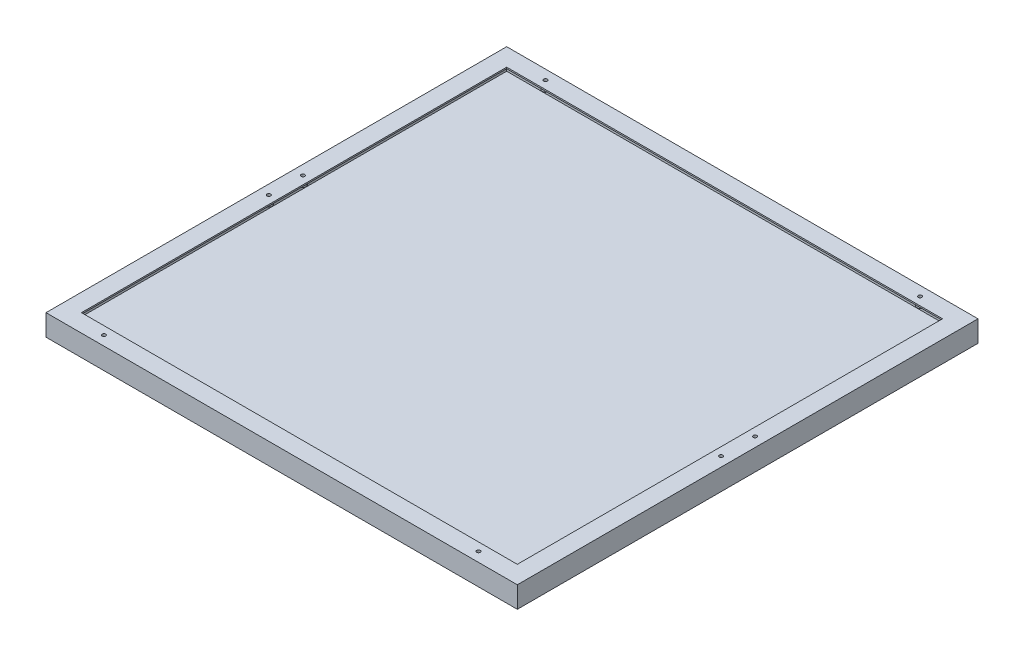
from build123d import *

# Parameters (mm, degrees)
SKETCH1_W                      = 665
SKETCH1_H                      = 650
BOSS_EXTRUDE1_DEPTH            = 30
F_8_0_199_DIAMETER_HOLE1_D     = 5.0546
F_8_0_199_DIAMETER_HOLE1_DEPTH = 9.65
SKETCH4_W                      = 615
SKETCH4_H                      = 600
CUT_EXTRUDE1_DEPTH             = 20
SHELL_T                        = -2


with BuildPart() as part:
    # Sketch1 → Boss-Extrude1 (new body)
    with BuildSketch(Plane(origin=(0, 0, 0), x_dir=(1, 0, 0), z_dir=(0, 1, 0))):
        with Locations((332.5, 325)):
            Rectangle(SKETCH1_W, SKETCH1_H)
    extrude(amount=-BOSS_EXTRUDE1_DEPTH)

    # #8 (0.199) Diameter Hole1
    with Locations(Plane(origin=(0, 0, 0), x_dir=(1, 0, 0), z_dir=(0, 1, 0))):
        with Locations((68.25, 13.5), (13.5, 301), (596.75, 13.5), (651.5, 301), (651.5, 349), (596.75, 636.5), (68.25, 636.5), (13.5, 349)):
            Hole(F_8_0_199_DIAMETER_HOLE1_D / 2, depth=F_8_0_199_DIAMETER_HOLE1_DEPTH)

    # Sketch4 → Cut-Extrude1 (cut)
    with BuildSketch(Plane(origin=(0, 0, 0), x_dir=(1, 0, 0), z_dir=(0, 1, 0))):
        with Locations((332.5, 325)):
            Rectangle(SKETCH4_W, SKETCH4_H)
    extrude(amount=-CUT_EXTRUDE1_DEPTH, mode=Mode.SUBTRACT)

    # Shell
    shell_openings = [part.faces().sort_by_distance(p)[0] for p in [
        (25, -10, -325),
        (332.5, -10, -25),
        (640, -10, -325),
        (332.5, -10, -625),
        (332.5, -20, -325),
    ]]
    offset(amount=SHELL_T, openings=shell_openings, kind=Kind.INTERSECTION)


solid = part.part
